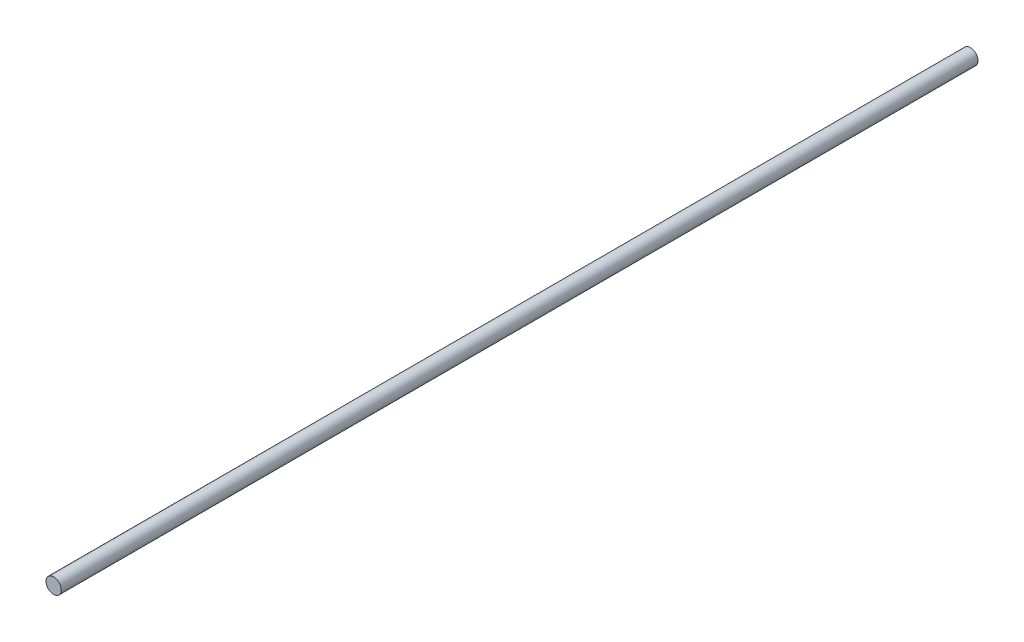
from build123d import *

# Parameters (mm, degrees)
SKETCH1_R           = 2.5
BOSS_EXTRUDE1_DEPTH = 300


with BuildPart() as part:
    # Sketch1 → Boss-Extrude1 (new body)
    with BuildSketch(Plane.XY):
        Circle(SKETCH1_R)
    extrude(amount=BOSS_EXTRUDE1_DEPTH)


solid = part.part
